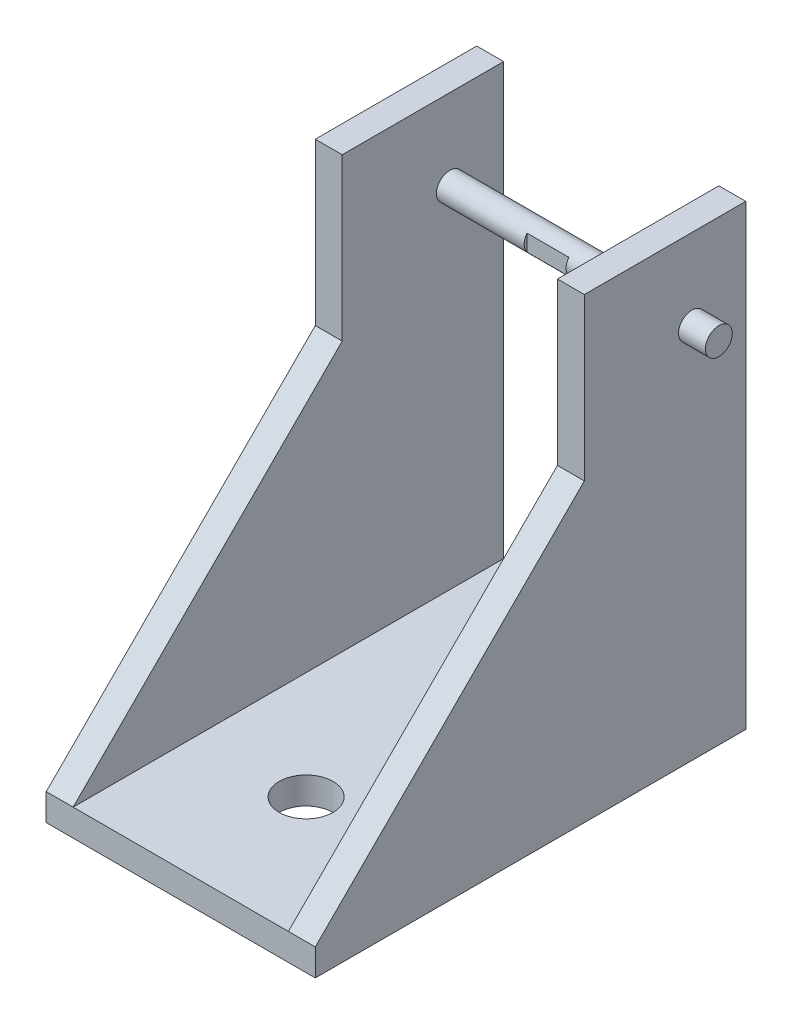
from build123d import *

# Parameters (mm, degrees)
SKETCH2_W                = 63.5
SKETCH2_H                = 6.35
BASE_DEPTH               = 101.6
RIB_DEPTH                = 6.35
CUT_EXTRUDE1_DEPTH       = 159.876949241
CUT_EXTRUDE1_DEPTH_BACK  = 159.876949241
SKETCH5_R                = 3.175
BOSS_EXTRUDE1_DEPTH      = 63.5
BOSS_EXTRUDE1_DEPTH_BACK = 12.7
SKETCH5_2_R              = 3.175
CUT_EXTRUDE2_REACH       = 161.763
SKETCH6_R                = 6.35
SKETCH7_W                = 9.883303814
SKETCH7_H                = 2.121203366
CUT_EXTRUDE3_DEPTH       = 25.4


with BuildPart() as part:
    # Sketch2 → Base (new body)
    with BuildSketch(Plane.XY):
        with Locations((31.75, 3.175)):
            Rectangle(SKETCH2_W, SKETCH2_H)
    extrude(amount=BASE_DEPTH)

    # Sketch4 → Rib (add)
    with BuildSketch(Plane(origin=(63.5, 0, 0), x_dir=(0, 0, -1), z_dir=(1, 0, 0))):
        Polygon((0, 107.95), (0, 6.35), (-101.6, 6.35), (-38.1, 69.85), (-38.1, 107.95), align=None)
    rib = extrude(amount=-RIB_DEPTH)

    # RibCopy: Rib across plane
    add(rib.mirror(Plane.ZY.offset(-31.75)))

    # Sketch5 → Cut-Extrude1 (cut, two sides: drawn at the far end of the back side and taken through both)
    with BuildSketch(Plane.ZY.offset(-57.15).offset(-CUT_EXTRUDE1_DEPTH_BACK)):
        with Locations((12.7, 88.9)):
            Circle(SKETCH5_R)
    extrude(amount=CUT_EXTRUDE1_DEPTH + CUT_EXTRUDE1_DEPTH_BACK, mode=Mode.SUBTRACT)

    # Sketch5_2 → Boss-Extrude1 (add, two sides: drawn at the far end of the back side and taken through both)
    with BuildSketch(Plane.ZY.offset(-57.15).offset(-BOSS_EXTRUDE1_DEPTH_BACK)):
        with Locations((12.7, 88.9)):
            Circle(SKETCH5_2_R)
    extrude(amount=BOSS_EXTRUDE1_DEPTH + BOSS_EXTRUDE1_DEPTH_BACK)

    # Sketch6 → Cut-Extrude2 (cut, up to next)
    with BuildSketch(Plane(origin=(0, 6.35, 0), x_dir=(-1, 0, 0), z_dir=(0, 1, 0)), mode=Mode.PRIVATE) as cut_extrude2_sk1:
        with Locations((-31.75, 72.023550981)):
            Circle(SKETCH6_R)
    cut_extrude2_tool1 = extrude(cut_extrude2_sk1.sketch, amount=-CUT_EXTRUDE2_REACH, mode=Mode.PRIVATE) & part.part
    # Sketch6 → Cut-Extrude2 (cut, up to next)
    with BuildSketch(Plane(origin=(0, 6.35, 0), x_dir=(-1, 0, 0), z_dir=(0, 1, 0)), mode=Mode.PRIVATE) as cut_extrude2_sk2:
        with Locations((-31.75, 32.114477008)):
            Circle(SKETCH6_R)
    cut_extrude2_tool2 = extrude(cut_extrude2_sk2.sketch, amount=-CUT_EXTRUDE2_REACH, mode=Mode.PRIVATE) & part.part
    add(cut_extrude2_tool1.solids().sort_by_distance((31.75, 6.35, 72.023551))[0], mode=Mode.SUBTRACT)
    add(cut_extrude2_tool2.solids().sort_by_distance((31.75, 6.35, 32.114477))[0], mode=Mode.SUBTRACT)

    # Sketch7 → Cut-Extrude3 (cut)
    with BuildSketch(Plane(origin=(0, 107.95, 0), x_dir=(-1, 0, 0), z_dir=(0, 1, 0))):
        with Locations((-32.019903214, 16.271172427)):
            Rectangle(SKETCH7_W, SKETCH7_H)
    extrude(amount=-CUT_EXTRUDE3_DEPTH, mode=Mode.SUBTRACT)


solid = part.part
